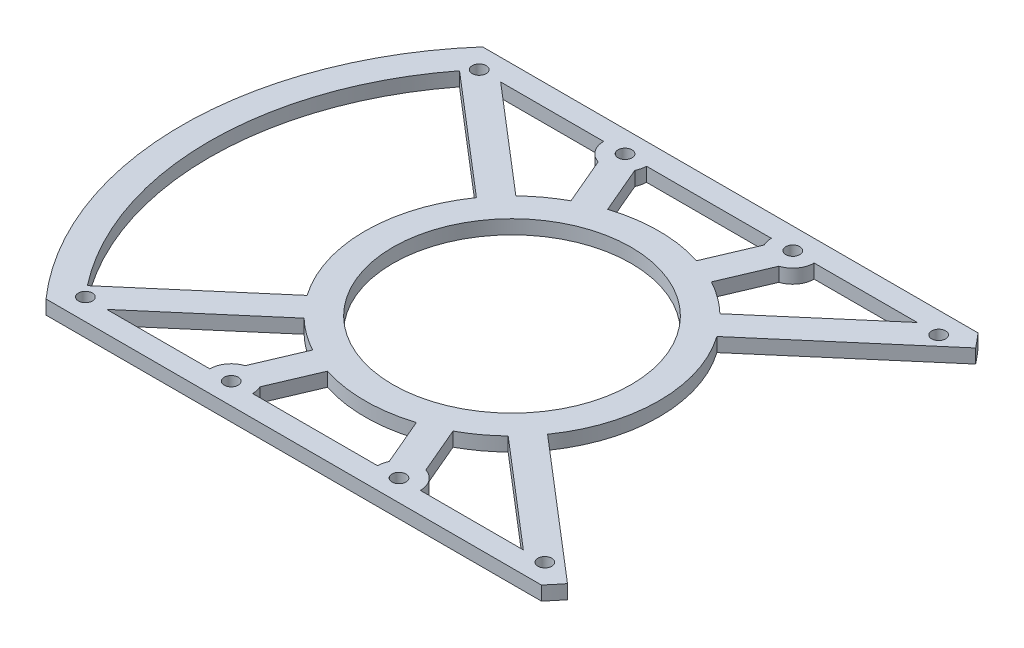
from build123d import *

# Parameters (mm, degrees)
SKETCH1_R           = 75
BOSS_EXTRUDE1_DEPTH = 3.175
CUT_EXTRUDE1_DEPTH  = 3.175
SKETCH3_R           = 1.5875
CUT_EXTRUDE2_DEPTH  = 3.175
SKETCH4_R           = 27.051
CUT_EXTRUDE3_DEPTH  = 3.175
CUT_EXTRUDE4_DEPTH  = 3.175


with BuildPart() as part:
    # Sketch1 → Boss-Extrude1 (new body)
    with BuildSketch(Plane(origin=(0, 0, 0), x_dir=(1, 0, 0), z_dir=(0, 1, 0))):
        Circle(SKETCH1_R)
    extrude(amount=BOSS_EXTRUDE1_DEPTH)

    # Sketch2 → Cut-Extrude1 (cut)
    with BuildSketch(Plane(origin=(0, 3.175, 0), x_dir=(1, 0, 0), z_dir=(0, 1, 0))):
        with BuildLine():
            Line((-56.262005909, -49.594220339), (56.262005909, -49.594220339))
            ThreePointArc((56.262005909, -49.594220339), (0, -75), (-56.262005909, -49.594220339))
        make_face()
        with BuildLine():
            Line((-56.262005909, 49.594220339), (56.262005909, 49.594220339))
            ThreePointArc((56.262005909, 49.594220339), (0, 75), (-56.262005909, 49.594220339))
        make_face()
    extrude(amount=-CUT_EXTRUDE1_DEPTH, mode=Mode.SUBTRACT)

    # Sketch3 → Cut-Extrude2 (cut)
    with BuildSketch(Plane(origin=(0, 3.175, 0), x_dir=(1, 0, 0), z_dir=(0, 1, 0))):
        with Locations((-52.180304588, 44.729838125)):
            Circle(SKETCH3_R)
        with Locations((-19.05, 44.729838125)):
            Circle(SKETCH3_R)
        with Locations((19.05, 44.729838125)):
            Circle(SKETCH3_R)
        with Locations((52.180304588, 44.729838125)):
            Circle(SKETCH3_R)
        with Locations((52.180304588, -44.729838125)):
            Circle(SKETCH3_R)
        with Locations((19.05, -44.729838125)):
            Circle(SKETCH3_R)
        with Locations((-19.05, -44.729838125)):
            Circle(SKETCH3_R)
        with Locations((-52.180304588, -44.729838125)):
            Circle(SKETCH3_R)
    extrude(amount=-CUT_EXTRUDE2_DEPTH, mode=Mode.SUBTRACT)

    # Sketch4 → Cut-Extrude3 (cut)
    with BuildSketch(Plane(origin=(0, 3.175, 0), x_dir=(1, 0, 0), z_dir=(0, 1, 0))):
        with BuildLine():
            Line((-47.315937317, 44.741895283), (-23.177806764, 24.050282215))
            ThreePointArc((-23.177806764, 24.050282215), (-19.742091457, 26.942097653), (-15.949506316, 29.346891646))
            Line((-15.949506316, 29.346891646), (-20.527078848, 40.095137229))
            ThreePointArc((-20.527078848, 40.095137229), (-22.980849122, 41.864416778), (-23.914367271, 44.741895283))
            Line((-23.914367271, 44.741895283), (-47.315937317, 44.741895283))
        make_face()
        with BuildLine():
            ThreePointArc((10.107278818, 31.835039122), (0, 33.401), (-10.107278818, 31.835039122))
            Line((-10.107278818, 31.835039122), (-14.68485135, 42.583284705))
            ThreePointArc((-14.68485135, 42.583284705), (-14.312069768, 43.627916425), (-14.185617786, 44.729838125))
            Line((-14.185617786, 44.729838125), (14.185617786, 44.729838125))
            ThreePointArc((14.185617786, 44.729838125), (14.312069768, 43.627916425), (14.68485135, 42.583284705))
            Line((14.68485135, 42.583284705), (10.107278818, 31.835039122))
        make_face()
        with BuildLine():
            ThreePointArc((15.949506316, 29.346891646), (19.742091457, 26.942097653), (23.177806764, 24.050282215))
            Line((23.177806764, 24.050282215), (47.315937317, 44.741895283))
            Line((47.315937317, 44.741895283), (23.914382214, 44.729838125))
            ThreePointArc((23.914382214, 44.729838125), (22.977294896, 41.859547352), (20.527078848, 40.095137229))
            Line((20.527078848, 40.095137229), (15.949506316, 29.346891646))
        make_face()
        Circle(SKETCH4_R)
        with BuildLine():
            Line((-23.177806764, -24.050282215), (-47.315937317, -44.741895283))
            Line((-47.315937317, -44.741895283), (-23.914382214, -44.729838125))
            ThreePointArc((-23.914382214, -44.729838125), (-22.977294896, -41.859547352), (-20.527078848, -40.095137229))
            Line((-20.527078848, -40.095137229), (-15.949506316, -29.346891646))
            ThreePointArc((-15.949506316, -29.346891646), (-19.742091457, -26.942097653), (-23.177806764, -24.050282215))
        make_face()
        with BuildLine():
            ThreePointArc((-10.107278818, -31.835039122), (0, -33.401), (10.107278818, -31.835039122))
            Line((10.107278818, -31.835039122), (14.68485135, -42.583284705))
            ThreePointArc((14.68485135, -42.583284705), (14.312069768, -43.627916425), (14.185617786, -44.729838125))
            Line((14.185617786, -44.729838125), (-14.185617786, -44.729838125))
            ThreePointArc((-14.185617786, -44.729838125), (-14.312069768, -43.627916425), (-14.68485135, -42.583284705))
            Line((-14.68485135, -42.583284705), (-10.107278818, -31.835039122))
        make_face()
        with BuildLine():
            ThreePointArc((23.177806764, -24.050282215), (19.742091457, -26.942097653), (15.949506316, -29.346891646))
            Line((15.949506316, -29.346891646), (20.527078848, -40.095137229))
            ThreePointArc((20.527078848, -40.095137229), (22.977294896, -41.859547352), (23.914382214, -44.729838125))
            Line((23.914382214, -44.729838125), (47.315937317, -44.741895283))
            Line((47.315937317, -44.741895283), (23.177806764, -24.050282215))
        make_face()
    extrude(amount=-CUT_EXTRUDE3_DEPTH, mode=Mode.SUBTRACT)

    # Sketch5 → Cut-Extrude4 (cut)
    with BuildSketch(Plane(origin=(0, 3.175, 0), x_dir=(1, 0, 0), z_dir=(0, 1, 0))):
        with BuildLine():
            Line((58.957481542, 46.357473725), (27.31053772, 19.229179141))
            ThreePointArc((27.31053772, 19.229179141), (33.401, 0), (27.31053772, -19.229179141))
            Line((27.31053772, -19.229179141), (58.957481542, -46.357473725))
            ThreePointArc((58.957481542, -46.357473725), (75, 0), (58.957481542, 46.357473725))
        make_face()
        with BuildLine():
            Line((-54.190960711, 42.271531589), (-27.31053772, 19.229179141))
            ThreePointArc((-27.31053772, 19.229179141), (-33.401, 0), (-27.31053772, -19.229179141))
            Line((-27.31053772, -19.229179141), (-54.190960711, -42.271531589))
            ThreePointArc((-54.190960711, -42.271531589), (-68.728033622, 0), (-54.190960711, 42.271531589))
        make_face()
    extrude(amount=-CUT_EXTRUDE4_DEPTH, mode=Mode.SUBTRACT)


solid = part.part
